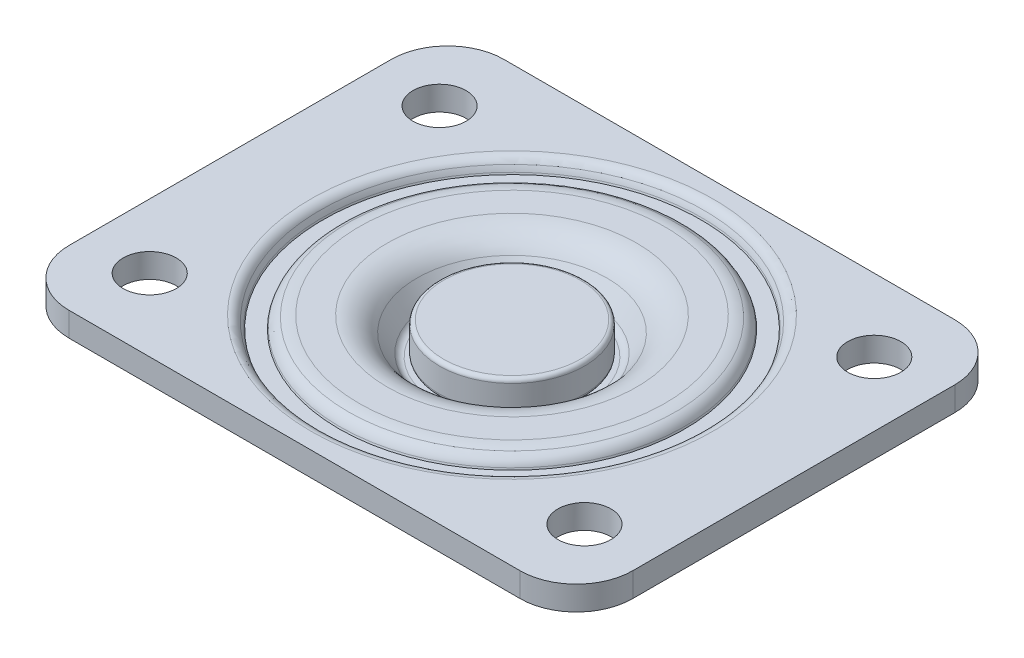
from build123d import *

# Parameters (mm, degrees)
SKETCH1_W           = 70
SKETCH1_H           = 54
BOSS_EXTRUDE1_DEPTH = 3
FILLET1_R           = 4
FILLET2_R           = 1.5
FILLET3_R           = 7
SKETCH6_R           = 3.3
CUT_EXTRUDE1_DEPTH  = 48.919202831
FILLET4_R           = 4.5
FILLET5_R           = 1
FILLET6_R           = 0.5


with BuildPart() as part:
    # Sketch1 → Boss-Extrude1 (new body)
    with BuildSketch(Plane(origin=(0, 0, 0), x_dir=(1, 0, 0), z_dir=(0, 1, 0))):
        Rectangle(SKETCH1_W, SKETCH1_H)
    extrude(amount=BOSS_EXTRUDE1_DEPTH)

    # Sketch2 → Revolve1 (revolve)
    with BuildSketch(Plane.XY):
        Polygon((-14.75, 0), (-11.599066078, -4.5), (-5, -4.5), (-5, -15.5), (0, -15.5), (0, 0), align=None)
    revolve(axis=Axis((0, -15.5, 0), (0, 1, 0)))

    # Fillet1
    fillet1_edges = [part.edges().sort_by_distance(p)[0] for p in [
        (11.599066078, -4.5, 0),
    ]]
    fillet(fillet1_edges, radius=FILLET1_R)

    # Fillet2
    fillet2_edges = [part.edges().sort_by_distance(p)[0] for p in [
        (14.75, 0, 0),
    ]]
    fillet(fillet2_edges, radius=FILLET2_R)

    # Fillet3
    fillet3_edges = [part.edges().sort_by_distance(p)[0] for p in [
        (35, 1.5, -27),
        (35, 1.5, 27),
        (-35, 1.5, -27),
        (-35, 1.5, 27),
    ]]
    fillet(fillet3_edges, radius=FILLET3_R)

    # Sketch3 → Revolve2 (revolve)
    with BuildSketch(Plane(origin=(0, 0, 0), x_dir=(0, 0, -1), z_dir=(1, 0, 0))):
        with BuildLine():
            Line((20.29, 0), (20.502160809, -0.367473301))
            ThreePointArc((20.502160809, -0.367473301), (22.52, -1.532473301), (24.537839191, -0.367473301))
            Line((24.537839191, -0.367473301), (24.75, 0))
            Line((24.75, 0), (20.29, 0))
        make_face()
    revolve(axis=Axis((0, 3.925, 0), (0, -1, 0)))

    # Sketch4 → Cut-Revolve1 (revolve, cut)
    with BuildSketch(Plane(origin=(0, 0, 0), x_dir=(0, 0, -1), z_dir=(1, 0, 0))):
        with BuildLine():
            Line((0, 3), (0, 2.5))
            Line((0, 2.5), (9, 2.5))
            Line((9, 2.5), (9, -1))
            ThreePointArc((9, -1), (8.853553391, -1.353553391), (8.5, -1.5))
            Line((8.5, -1.5), (9.999066078, -1.5))
            Line((9.999066078, -1.5), (13.15, 3))
            Line((13.15, 3), (0, 3))
        make_face()
    revolve(axis=Axis((0, 3.925, 0), (0, -1, 0)), mode=Mode.SUBTRACT)

    # Sketch5 → Cut-Revolve2 (revolve, cut)
    with BuildSketch(Plane(origin=(0, 0, 0), x_dir=(0, 0, -1), z_dir=(1, 0, 0))):
        with BuildLine():
            Line((21.413255939, 1.705375654), (21.488006564, 1.5))
            Line((21.488006564, 1.5), (23.488006564, 1.5))
            Line((23.488006564, 1.5), (23.562010813, 1.703325005))
            ThreePointArc((23.562010813, 1.703325005), (23.695887988, 2.028345161), (23.856350384, 2.34109589))
            ThreePointArc((23.856350384, 2.34109589), (24.332840552, 2.823259689), (24.987277463, 3))
            Line((24.987277463, 3), (18.999733381, 3))
            ThreePointArc((18.999733381, 3), (19.682644585, 2.941272927), (20.345503101, 2.766816143))
            ThreePointArc((20.345503101, 2.766816143), (20.997863005, 2.355284), (21.413255939, 1.705375654))
        make_face()
    revolve(axis=Axis((0, 3.925, 0), (0, -1, 0)), mode=Mode.SUBTRACT)

    # Sketch6 → Cut-Extrude1 (cut, through all)
    with BuildSketch(Plane(origin=(0, 3, 0), x_dir=(1, 0, 0), z_dir=(0, 1, 0))):
        with Locations((-27, 18)):
            Circle(SKETCH6_R)
        with Locations((27, 18)):
            Circle(SKETCH6_R)
        with Locations((27, -18)):
            Circle(SKETCH6_R)
        with Locations((-27, -18)):
            Circle(SKETCH6_R)
    extrude(amount=-CUT_EXTRUDE1_DEPTH, mode=Mode.SUBTRACT)

    # Fillet4
    fillet4_edges = [part.edges().sort_by_distance(p)[0] for p in [
        (0, 3, 13.15),
    ]]
    fillet(fillet4_edges, radius=FILLET4_R)

    # Fillet5
    fillet5_edges = [part.edges().sort_by_distance(p)[0] for p in [
        (0, -1.5, 9.999066078),
    ]]
    fillet(fillet5_edges, radius=FILLET5_R)

    # Fillet6
    fillet6_edges = [part.edges().sort_by_distance(p)[0] for p in [
        (0, 2.5, 9),
        (0, 0, 20.29),
        (0, 0, 24.75),
    ]]
    fillet(fillet6_edges, radius=FILLET6_R)


solid = part.part
